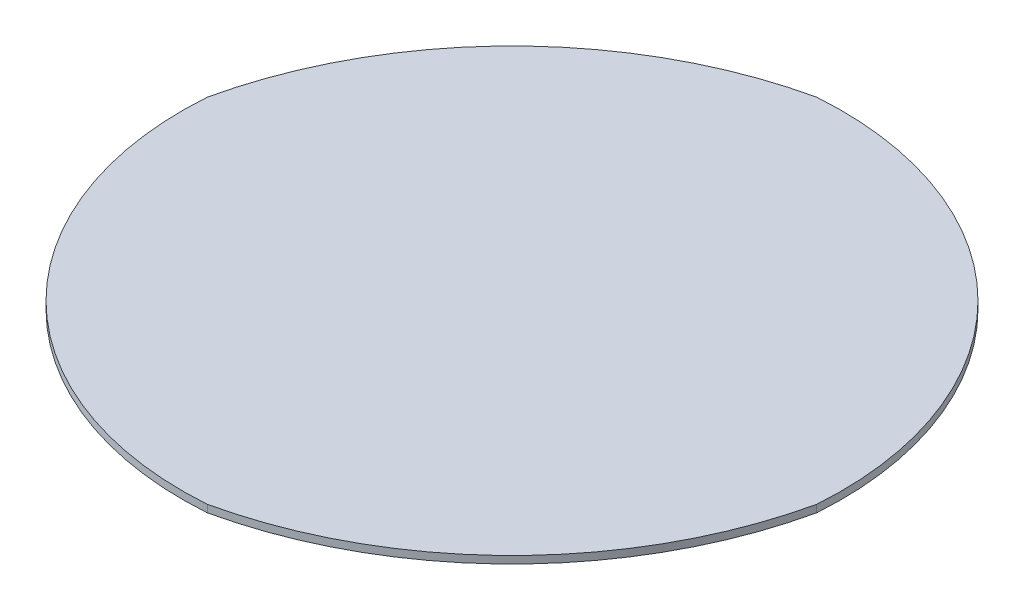
from build123d import *

# Parameters (mm, degrees)
SKETCH2_R               = 89
BOSS_EXTRUDE1_DEPTH     = 2
CUT_EXTRUDE2_DEPTH      = 2
CUT_EXTRUDE2_DEPTH_BACK = 22


with BuildPart() as part:
    # Sketch2 → Boss-Extrude1 (new body)
    with BuildSketch(Plane(origin=(0, 0, 0), x_dir=(1, 0, 0), z_dir=(0, 1, 0))):
        Circle(SKETCH2_R)
    extrude(amount=BOSS_EXTRUDE1_DEPTH)

    # Sketch1 → Cut-Extrude2 (cut, two sides)
    with BuildSketch(Plane(origin=(0, 0, 0), x_dir=(1, 0, 0), z_dir=(0, 1, 0))) as cut_extrude2_sk:
        with BuildLine():
            Line((90, 0), (186.2474928, -76.185882947))
            Line((186.2474928, -76.185882947), (27.022307814, -178.450111289))
            Line((27.022307814, -178.450111289), (0, -90))
            ThreePointArc((0, -90), (59.595249678, -59.595249678), (90, 0))
        make_face()
        with BuildLine():
            ThreePointArc((0, 90), (-59.595249678, 59.595249678), (-90, 0))
            Line((-90, 0), (-148.807489937, 41.634610526))
            Line((-148.807489937, 41.634610526), (-57.628187995, 163.6657734))
            Line((-57.628187995, 163.6657734), (0, 90))
        make_face()
    extrude(amount=CUT_EXTRUDE2_DEPTH, mode=Mode.SUBTRACT)
    extrude(cut_extrude2_sk.sketch, amount=-CUT_EXTRUDE2_DEPTH_BACK, mode=Mode.SUBTRACT)


solid = part.part
